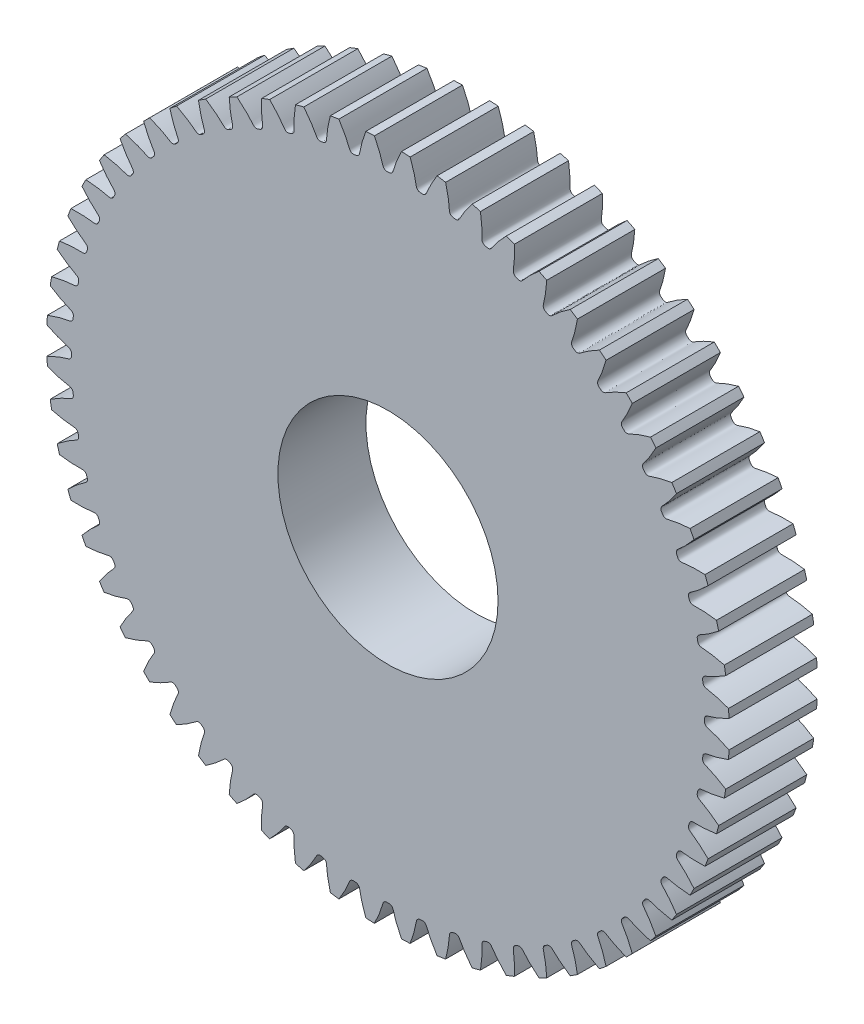
from build123d import *

# Parameters (mm, degrees)
SKETCHREVOLVESPURGEAR2_W       = 4
SKETCHREVOLVESPURGEAR2_H       = 15.499999767
TOOTHEXTRUDECUTSPURGEAR2_DEPTH = 2
PATTERNSPURGEAR2_COUNT         = 60
BOREREVOLVESKETCH_W            = 4
BOREREVOLVESKETCH_H            = 5


with BuildPart() as part:
    # SketchRevolveSpurGear2 → SpurGear2 (revolve)
    with BuildSketch(Plane(origin=(0, 0, 0), x_dir=(0, 0, -1), z_dir=(1, 0, 0))):
        with Locations((0, 7.749999884)):
            Rectangle(SKETCHREVOLVESPURGEAR2_W, SKETCHREVOLVESPURGEAR2_H)
    revolve(axis=Axis((0, 0, 0), (0, 0, -1)))

    # SketchToothSpurGear2 → ToothExtrudeCutSpurGear2 (cut, symmetric)
    with BuildSketch(Plane.XY):
        with BuildLine():
            ThreePointArc((15.512313963, 0.627481699), (15.524999767, 0), (15.512313963, -0.627481699))
            add(Edge.make_bspline(
                [(15.512313963, -0.627481699), (15.470193591, -0.605930108), (15.407448616, -0.574683215), (15.32415719, -0.534954025), (15.26375607, -0.506967493), (15.204651836, -0.48038004), (15.146868016, -0.455159095), (15.090427571, -0.431271732), (15.035352888, -0.40868469), (14.981665787, -0.387364355), (14.929387474, -0.367276868), (14.878538677, -0.348387785), (14.829139159, -0.330663312), (14.781209421, -0.314065967), (14.734764632, -0.298570013), (14.689836117, -0.284106862), (14.646395426, -0.270757941), (14.585121431, -0.2521545), (14.5303874, -0.239512562), (14.485644434, -0.22013724), (14.465659344, -0.20946999), (14.444420746, -0.195201636), (14.421576792, -0.174964158), (14.398318827, -0.14537653), (14.380003302, -0.105133827), (14.373032545, -0.054503387), (14.376071476, 0), (14.373032545, 0.054503387), (14.380003302, 0.105133827), (14.398318827, 0.14537653), (14.421576792, 0.174964158), (14.444420746, 0.195201636), (14.465659344, 0.20946999), (14.485644434, 0.22013724), (14.5303874, 0.239512562), (14.585121431, 0.2521545), (14.646395426, 0.270757941), (14.689836117, 0.284106862), (14.734764632, 0.298570013), (14.781209421, 0.314065967), (14.829139159, 0.330663312), (14.878538677, 0.348387785), (14.929387474, 0.367276868), (14.981665787, 0.387364355), (15.035352888, 0.40868469), (15.090427571, 0.431271732), (15.146868016, 0.455159095), (15.204651836, 0.48038004), (15.26375607, 0.506967493), (15.32415719, 0.534954025), (15.407448616, 0.574683215), (15.470193591, 0.605930108), (15.512313963, 0.627481699)],
                knots=[0, 0, 0, 0, 0.05176586, 0.076685537, 0.100963046, 0.124598386, 0.147591557, 0.16994256, 0.191651394, 0.21271806, 0.233142557, 0.252924885, 0.272065045, 0.290563036, 0.308418859, 0.325632513, 0.342203998, 0.358133315, 0.395728589, 0.403326908, 0.411414611, 0.420483419, 0.431260975, 0.444674611, 0.46138654, 0.478964563, 0.5, 0.521035437, 0.53861346, 0.555325389, 0.568739025, 0.579516581, 0.588585389, 0.596673092, 0.604271411, 0.641866685, 0.657796002, 0.674367487, 0.691581141, 0.709436964, 0.727934955, 0.747075115, 0.766857443, 0.78728194, 0.808348606, 0.83005744, 0.852408443, 0.875401614, 0.899036954, 0.923314463, 0.94823414, 1, 1, 1, 1], degree=3))
        make_face()
    toothextrudecutspurgear2 = extrude(amount=TOOTHEXTRUDECUTSPURGEAR2_DEPTH, both=True, mode=Mode.SUBTRACT)

    # PatternSpurGear2: ToothExtrudeCutSpurGear2 ×60 about axis
    patternspurgear2_axis = Axis((0, 0, 55), (0, 0, -1))
    for i in range(1, PATTERNSPURGEAR2_COUNT):
        add(toothextrudecutspurgear2.rotate(patternspurgear2_axis, i * 360 / PATTERNSPURGEAR2_COUNT), mode=Mode.SUBTRACT)

    # BoreRevolveSketch → BoreRevolveCut (revolve, cut)
    with BuildSketch(Plane(origin=(0, 0, 0), x_dir=(0, 0, -1), z_dir=(1, 0, 0))):
        with Locations((0, 2.5)):
            Rectangle(BOREREVOLVESKETCH_W, BOREREVOLVESKETCH_H)
    revolve(axis=Axis((0, 0, 0), (0, 0, -1)), mode=Mode.SUBTRACT)


solid = part.part
